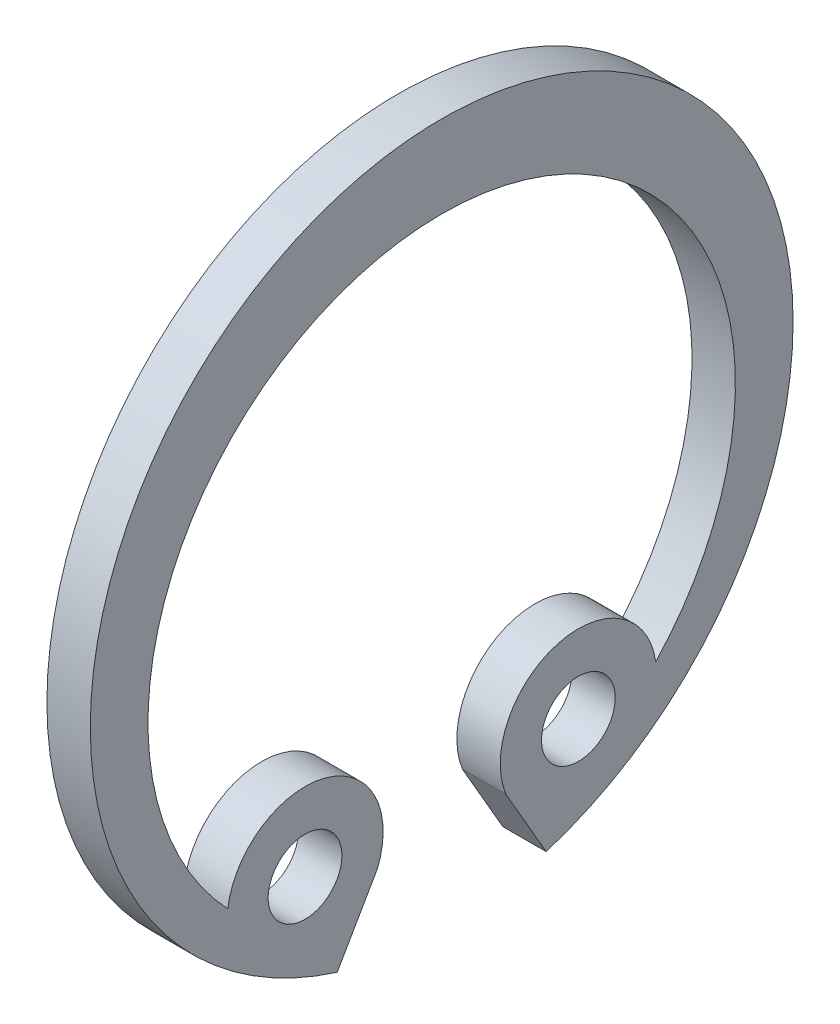
from build123d import *

# Parameters (mm, degrees)
BOSS_EXTRUDE1_DEPTH      = 0.5
BOSS_EXTRUDE1_DEPTH_BACK = 0.5
SKETCH1_R                = 0.85


with BuildPart() as part:
    # Sketch1 → Boss-Extrude1 (new, two sides: drawn at the far end of the back side and taken through both)
    with BuildSketch(Plane(origin=(0, 0, 0), x_dir=(0, 0, -1), z_dir=(1, 0, 0)).offset(-BOSS_EXTRUDE1_DEPTH_BACK)):
        with BuildLine():
            Line((-2.40796943, -7.733801344), (-1.478571429, -6.124036784))
            ThreePointArc((-1.478571429, -6.124036784), (-2.688100389, -3.716233413), (-4.932694682, -5.20696271))
            ThreePointArc((-4.932694682, -5.20696271), (0, 6.2), (4.932694682, -5.20696271))
            ThreePointArc((4.932694682, -5.20696271), (2.688100389, -3.716233413), (1.478571429, -6.124036784))
            Line((1.478571429, -6.124036784), (2.40796943, -7.733801344))
            ThreePointArc((2.40796943, -7.733801344), (0, 8.1), (-2.40796943, -7.733801344))
        make_face()
        with Locations((3.15, -5.455960044)):
            Circle(SKETCH1_R, mode=Mode.SUBTRACT)
        with Locations((-3.15, -5.455960044)):
            Circle(SKETCH1_R, mode=Mode.SUBTRACT)
    extrude(amount=BOSS_EXTRUDE1_DEPTH + BOSS_EXTRUDE1_DEPTH_BACK)


solid = part.part
